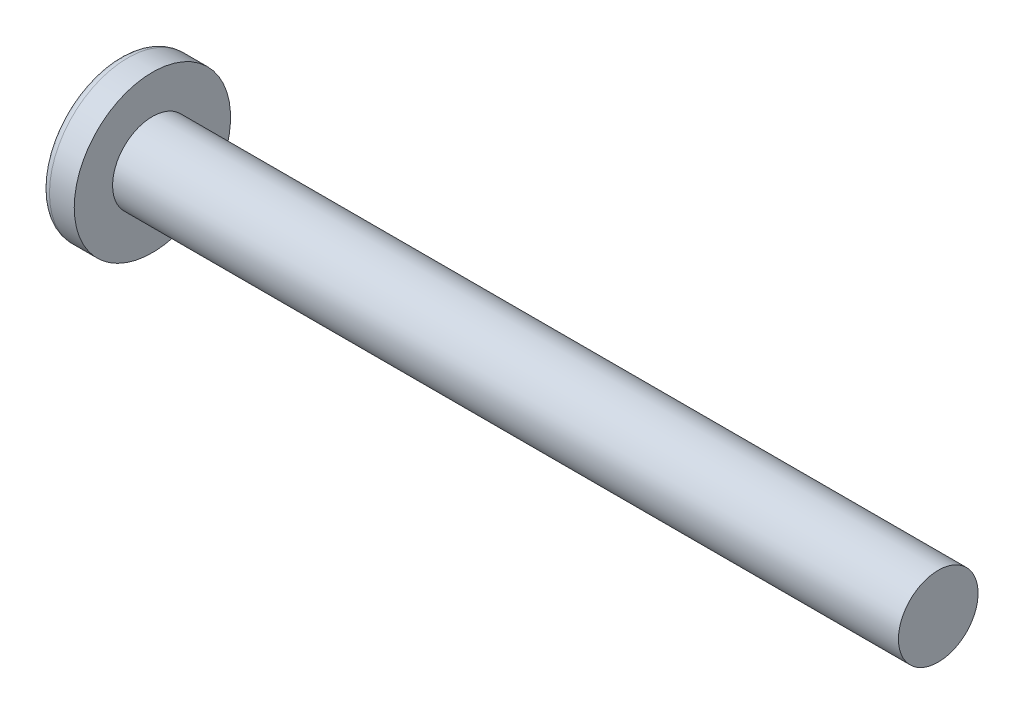
from build123d import *

# Parameters (mm, degrees)
SKETCH3_W         = 1.1684
SKETCH3_H         = 6.096
SKETCH4_W         = 0.5842
SKETCH4_H         = 0.5842
CIRPATTERN1_COUNT = 2
CIRPATTERN1_ANGLE = 90


with BuildPart() as part:
    # BodySke → Base-Revolve (revolve)
    with BuildSketch(Plane.XY):
        with BuildLine():
            Line((3.3782, 2.413), (3.3782, 4.7371))
            Line((3.3782, 4.7371), (1.87773671, 4.7371))
            ThreePointArc((1.87773671, 4.7371), (1.646685378, 4.681514944), (1.466197042, 4.526923944))
            ThreePointArc((1.466197042, 4.526923944), (0.375688687, 2.379221204), (0, 0))
            Line((0, 0), (51.0032, 0))
            Line((51.0032, 0), (51.0032, 2.413))
            Line((51.0032, 2.413), (3.3782, 2.413))
        make_face()
    revolve(axis=Axis((-25.4, 0, 0), (1, 0, 0)))

    # Sketch3 → Cut-Loft1 section 0
    with BuildSketch(Plane(origin=(0, 0, 0), x_dir=(0, 0, -1), z_dir=(1, 0, 0))):
        Rectangle(SKETCH3_W, SKETCH3_H)
    # Sketch4 → Cut-Loft1 section 1
    with BuildSketch(Plane(origin=(3.4798, 0, 0), x_dir=(0, 0, -1), z_dir=(1, 0, 0))):
        Rectangle(SKETCH4_W, SKETCH4_H)
    cut_loft1 = loft(mode=Mode.SUBTRACT)

    # CirPattern1: Cut-Loft1 ×2 about axis
    cirpattern1_axis = Axis((0, 0, 0), (1, 0, 0))
    for i in range(1, CIRPATTERN1_COUNT):
        add(cut_loft1.rotate(cirpattern1_axis, i * CIRPATTERN1_ANGLE / (CIRPATTERN1_COUNT - 1)), mode=Mode.SUBTRACT)


solid = part.part
